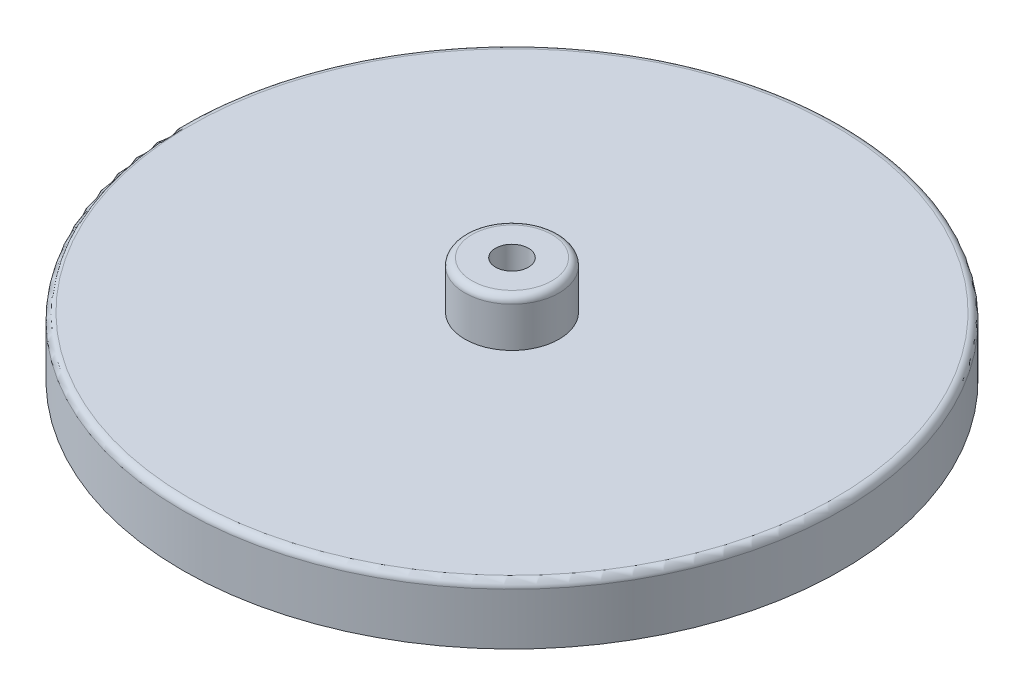
from build123d import *

# Parameters (mm, degrees)
SKETCH1_R           = 35.56
BOSS_EXTRUDE1_DEPTH = 6.35
SKETCH2_R           = 5.08
BOSS_EXTRUDE2_DEPTH = 5.08
SKETCH3_R           = 1.778
CUT_EXTRUDE1_DEPTH  = 12.43
SKETCH4_R           = 3.556
CUT_EXTRUDE2_DEPTH  = 2.54
FILLET1_R           = 0.762
FILLET2_R           = 0.762


with BuildPart() as part:
    # Sketch1 → Boss-Extrude1 (new body)
    with BuildSketch(Plane(origin=(0, 0, 0), x_dir=(1, 0, 0), z_dir=(0, 1, 0))):
        with Locations(Location((0, 0, 0), (0, 0, 270))):  # turned: the seam where the file's is
            Circle(SKETCH1_R)
    extrude(amount=BOSS_EXTRUDE1_DEPTH)

    # Sketch2 → Boss-Extrude2 (add)
    with BuildSketch(Plane(origin=(0, 6.35, 0), x_dir=(1, 0, 0), z_dir=(0, 1, 0))):
        with Locations(Location((0, 0, 0), (0, 0, 270))):  # turned: the seam where the file's is
            Circle(SKETCH2_R)
    extrude(amount=BOSS_EXTRUDE2_DEPTH)

    # Sketch3 → Cut-Extrude1 (cut, through all)
    with BuildSketch(Plane(origin=(0, 11.43, 0), x_dir=(1, 0, 0), z_dir=(0, 1, 0))):
        with Locations(Location((0, 0, 0), (0, 0, 270))):  # turned: the seam where the file's is
            Circle(SKETCH3_R)
    extrude(amount=-CUT_EXTRUDE1_DEPTH, mode=Mode.SUBTRACT)

    # Sketch4 → Cut-Extrude2 (cut)
    with BuildSketch(Plane.XZ):
        with Locations(Location((0, 0, 0), (0, 0, 270))):  # turned: the seam where the file's is
            Circle(SKETCH4_R)
    extrude(amount=-CUT_EXTRUDE2_DEPTH, mode=Mode.SUBTRACT)

    # Fillet1
    fillet1_edges = [part.edges().sort_by_distance(p)[0] for p in [
        (0, 11.43, -5.08),
    ]]
    fillet(fillet1_edges, radius=FILLET1_R)

    # Fillet2
    fillet2_edges = [part.edges().sort_by_distance(p)[0] for p in [
        (0, 6.35, -35.56),
    ]]
    fillet(fillet2_edges, radius=FILLET2_R)


solid = part.part
